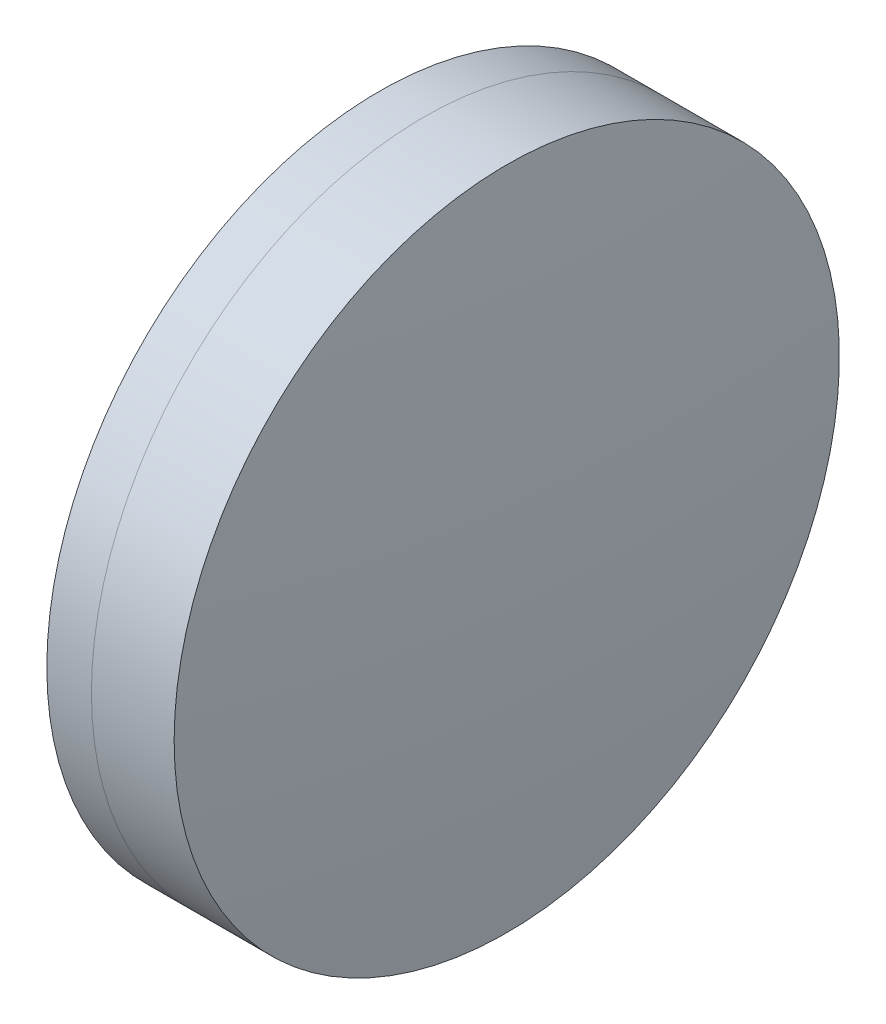
from build123d import *


with BuildPart() as part:
    # 草图1 one side → 旋转1 (revolve)
    with BuildSketch(Plane(origin=(0, 0, 0), x_dir=(1, 0, 0), z_dir=(0, 1, 0)), mode=Mode.PRIVATE) as revolve_1_sk:
        with BuildLine():
            ThreePointArc((329.92943661, 25.4), (326.956453114, 12.854343455), (325.957461954, 0))
            Line((325.957461954, 0), (337.957461954, 0))
            ThreePointArc((337.957461954, 0), (336.792493899, 12.908572463), (333.335236073, 25.4))
            Line((333.335236073, 25.4), (329.92943661, 25.4))
        make_face()
    revolve(revolve_1_sk.sketch.rotate(Axis((124.523309526, 0, 0), (1, 0, 0)), 180), axis=Axis((124.523309526, 0, 0), (1, 0, 0)))  # turned: the seam where the file's is


with BuildPart() as body_2:
    # 草图2 one side → 旋转3 (revolve)
    with BuildSketch(Plane(origin=(0, 0, 0), x_dir=(1, 0, 0), z_dir=(0, 1, 0)), mode=Mode.PRIVATE) as revolve_3_sk:
        with BuildLine():
            Line((339.651719192, 25.4), (333.335236073, 25.4))
            ThreePointArc((333.335236073, 25.4), (336.792493899, 12.908572463), (337.957461954, 0))
            Line((337.957461954, 0), (340.957461954, 0))
            ThreePointArc((340.957461954, 0), (340.63081088, 12.716770071), (339.651719192, 25.4))
        make_face()
    revolve(revolve_3_sk.sketch.rotate(Axis((-0.551919993, 0, 0), (1, 0, 0)), 180), axis=Axis((-0.551919993, 0, 0), (1, 0, 0)))  # turned: the seam where the file's is


solid = Compound([part.part, body_2.part])
